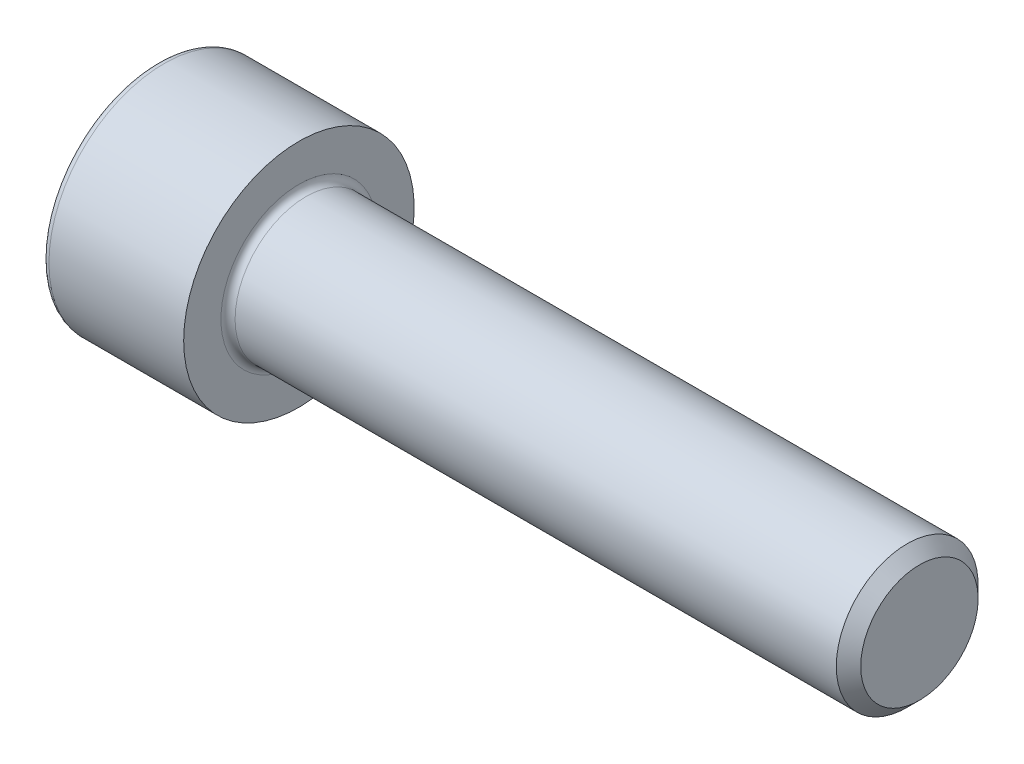
from build123d import *

# Parameters (mm, degrees)
FILLET1_R   = 0.4
FILLET2_R   = 0.4
HEX_2_DEPTH = 4


with BuildPart() as part:
    # BodySke → Base-Revolve (revolve)
    with BuildSketch(Plane.XY):
        Polygon((0, 0), (0, 6.5), (8, 6.5), (8, 4), (42.3095, 4), (43, 3.3095), (43, 0), align=None)
    revolve(axis=Axis((-31.75, 0, 0), (1, 0, 0)))

    # Fillet1
    fillet1_edges = [part.edges().sort_by_distance(p)[0] for p in [
        (8, -4, 0),
    ]]
    fillet(fillet1_edges, radius=FILLET1_R)

    # Fillet2
    fillet2_edges = [part.edges().sort_by_distance(p)[0] for p in [
        (0, -6.5, 0),
    ]]
    fillet(fillet2_edges, radius=FILLET2_R)

    # Sketch2 → Hex-PreBroach (revolve, cut)
    with BuildSketch(Plane.XY):
        Polygon((0, 3.0475), (4, 3.0475), (5.759474945, 0), (0, 0), align=None)
    revolve(axis=Axis((0, 0, 0), (1, 0, 0)), mode=Mode.SUBTRACT)

    # Sketch3 → Hex 2 (cut)
    with BuildSketch(Plane(origin=(0, 0, 0), x_dir=(0, 0.5, 0.866025404), z_dir=(-1, 0, 0))):
        Polygon((1.759474945, 3.0475), (-1.759474945, 3.0475), (-3.518949891, 0), (-1.759474945, -3.0475), (1.759474945, -3.0475), (3.518949891, 0), align=None)
    extrude(amount=-HEX_2_DEPTH, mode=Mode.SUBTRACT)


solid = part.part
